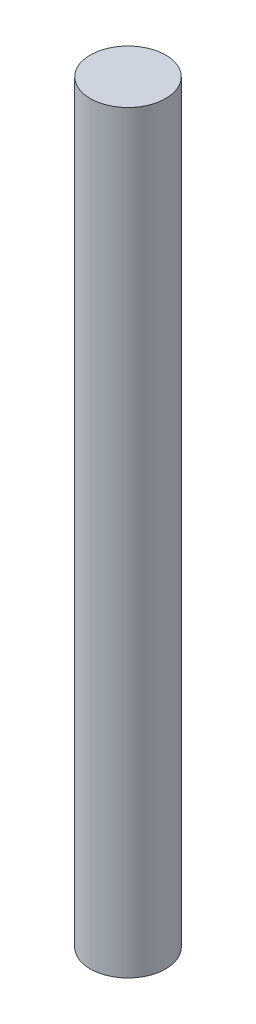
from build123d import *

# Parameters (mm, degrees)
SKETCH1_R           = 0.75
BOSS_EXTRUDE1_DEPTH = 15


with BuildPart() as part:
    # Sketch1 → Boss-Extrude1 (new body)
    with BuildSketch(Plane(origin=(0, 0, 0), x_dir=(1, 0, 0), z_dir=(0, 1, 0))):
        Circle(SKETCH1_R)
    extrude(amount=BOSS_EXTRUDE1_DEPTH)


solid = part.part
